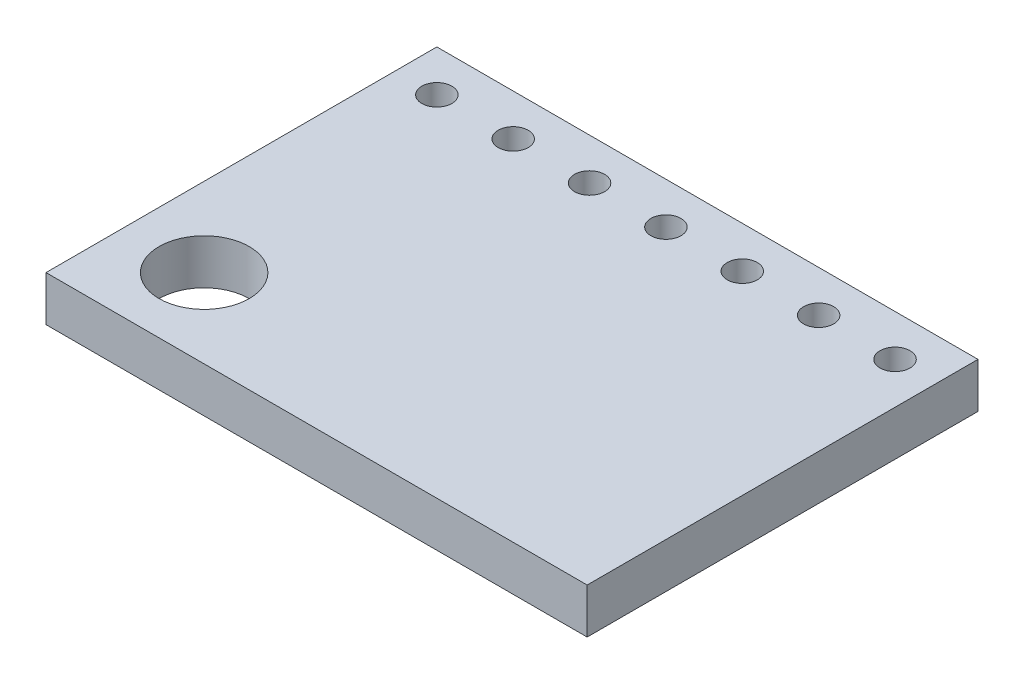
from build123d import *

# Parameters (mm, degrees)
SKETCH1_W           = 18
SKETCH1_H           = 13
SKETCH1_R           = 0.5
SKETCH1_R_2         = 1.5
BOSS_EXTRUDE1_DEPTH = 1.5


with BuildPart() as part:
    # Sketch1 → Boss-Extrude1 (new body)
    with BuildSketch(Plane(origin=(0, 0, 0), x_dir=(1, 0, 0), z_dir=(0, 1, 0))):
        with Locations((9, -6.5)):
            Rectangle(SKETCH1_W, SKETCH1_H)
        with Locations((1.38, -1.38)):
            Circle(SKETCH1_R, mode=Mode.SUBTRACT)
        with Locations((3.92, -1.38)):
            Circle(SKETCH1_R, mode=Mode.SUBTRACT)
        with Locations((6.46, -1.38)):
            Circle(SKETCH1_R, mode=Mode.SUBTRACT)
        with Locations((9, -1.38)):
            Circle(SKETCH1_R, mode=Mode.SUBTRACT)
        with Locations((11.54, -1.38)):
            Circle(SKETCH1_R, mode=Mode.SUBTRACT)
        with Locations((14.08, -1.38)):
            Circle(SKETCH1_R, mode=Mode.SUBTRACT)
        with Locations((16.62, -1.38)):
            Circle(SKETCH1_R, mode=Mode.SUBTRACT)
        with Locations((2.63, -10.37)):
            Circle(SKETCH1_R_2, mode=Mode.SUBTRACT)
    extrude(amount=-BOSS_EXTRUDE1_DEPTH)


solid = part.part
